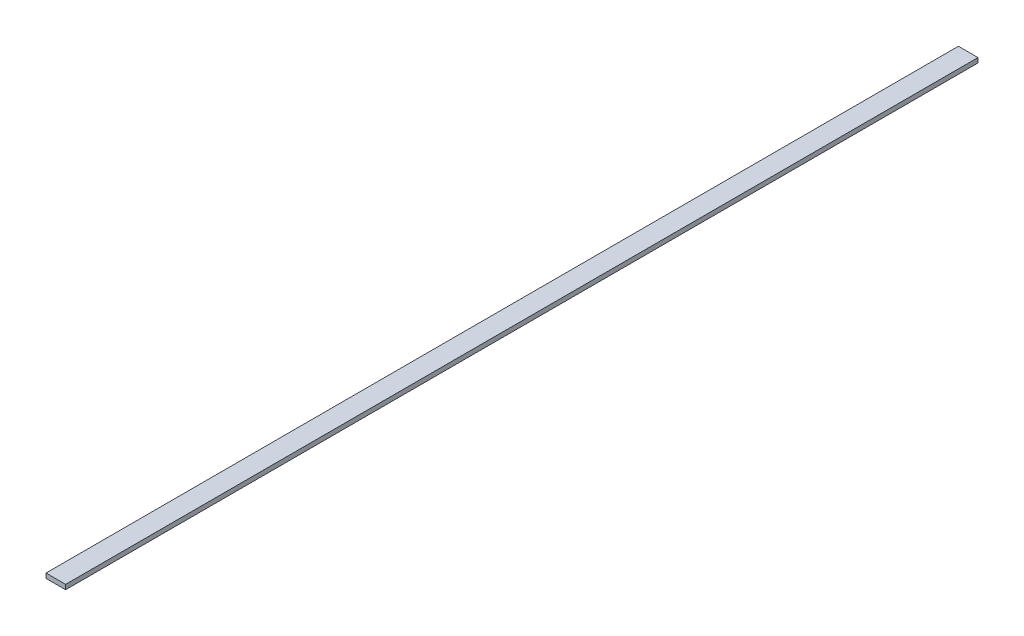
from build123d import *

# Parameters (mm, degrees)
SKETCH1_W           = 6.35
SKETCH1_H           = 1.51892
BOSS_EXTRUDE1_DEPTH = 295.41216


with BuildPart() as part:
    # Sketch1 → Boss-Extrude1 (new body)
    with BuildSketch(Plane.XY):
        with Locations((3.175, 0.75946)):
            Rectangle(SKETCH1_W, SKETCH1_H)
    extrude(amount=BOSS_EXTRUDE1_DEPTH)


solid = part.part
